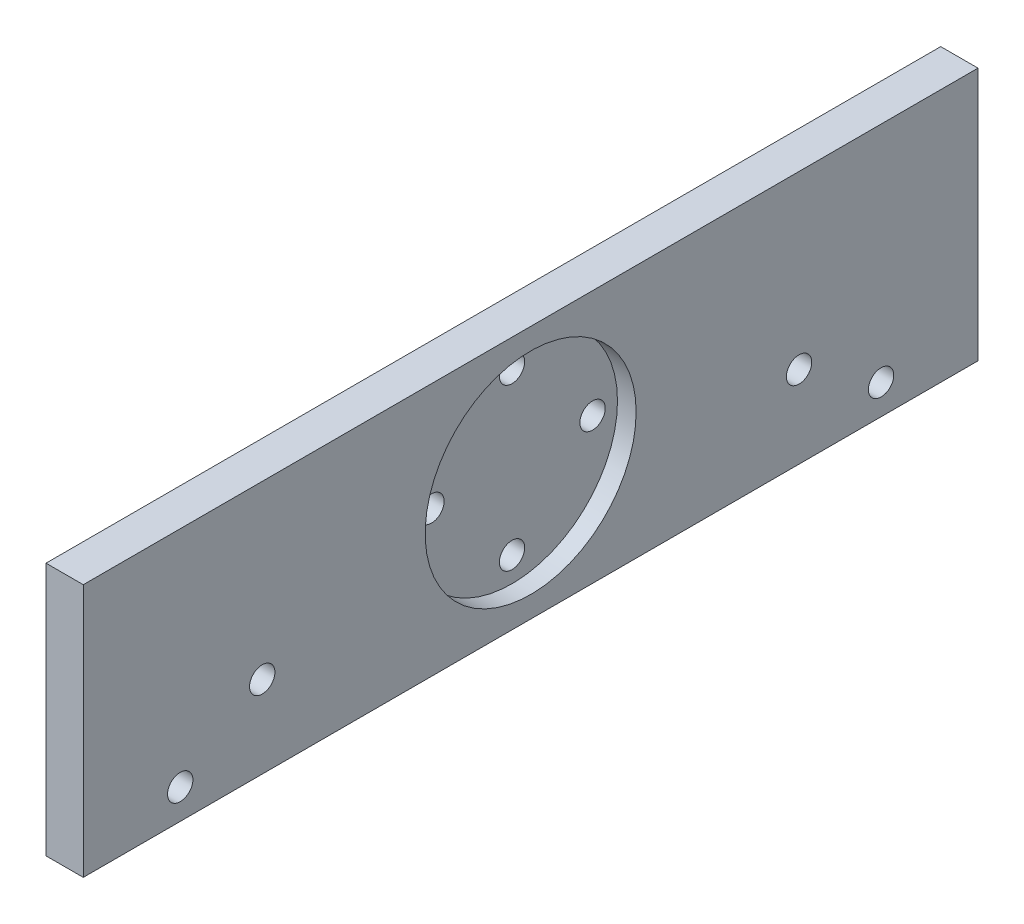
from build123d import *

# Parameters (mm, degrees)
SKETCH1_W                = 120
SKETCH1_H                = 34
BOSS_EXTRUDE1_DEPTH      = 5
CUT_EXTRUDE1_DEPTH       = 2.5
M3_CLEARANCE_HOLE1_D     = 3.4
M3_CLEARANCE_HOLE1_DEPTH = 15
M3_CLEARANCE_HOLE1_TIP   = 1.021463052
M3_CLEARANCE_HOLE3_D     = 3.4
M3_CLEARANCE_HOLE3_DEPTH = 15
M3_CLEARANCE_HOLE3_TIP   = 1.021463052


with BuildPart() as part:
    # Sketch1 → Boss-Extrude1 (new body)
    with BuildSketch(Plane(origin=(0, 0, 0), x_dir=(0, 0, -1), z_dir=(1, 0, 0))):
        with Locations((-60, 17)):
            Rectangle(SKETCH1_W, SKETCH1_H)
    extrude(amount=BOSS_EXTRUDE1_DEPTH)

    # Sketch2 → Cut-Extrude1 (cut)
    with BuildSketch(Plane(origin=(5, 0, 0), x_dir=(0, 0, -1), z_dir=(1, 0, 0))):
        with BuildLine():
            ThreePointArc((-45.85, 17), (-49.994439046, 27.005560954), (-60, 31.15))
            Line((-60, 31.15), (-60, 2.85))
            ThreePointArc((-60, 2.85), (-49.994439046, 6.994439046), (-45.85, 17))
        make_face()
        with BuildLine():
            Line((-60, 2.85), (-60, 31.15))
            ThreePointArc((-60, 31.15), (-74.15, 17), (-60, 2.85))
        make_face()
    extrude(amount=-CUT_EXTRUDE1_DEPTH, mode=Mode.SUBTRACT)

    # M3 Clearance Hole1
    with Locations(Plane(origin=(2.5, 0, 0), x_dir=(0, 0, -1), z_dir=(1, 0, 0))):
        with Locations((-60, 27.8), (-49.2, 17), (-60, 6.2), (-70.8, 17)):
            Hole(M3_CLEARANCE_HOLE1_D / 2, depth=M3_CLEARANCE_HOLE1_DEPTH)
            with Locations((0, 0, -(M3_CLEARANCE_HOLE1_DEPTH + M3_CLEARANCE_HOLE1_TIP / 2))):  # 118° drill point
                Cone(0, M3_CLEARANCE_HOLE1_D / 2, M3_CLEARANCE_HOLE1_TIP, mode=Mode.SUBTRACT)

    # M3 Clearance Hole3
    with Locations(Plane.ZY):
        with Locations((24, 11), (13, 4), (96, 11), (107, 4)):
            Hole(M3_CLEARANCE_HOLE3_D / 2, depth=M3_CLEARANCE_HOLE3_DEPTH)
            with Locations((0, 0, -(M3_CLEARANCE_HOLE3_DEPTH + M3_CLEARANCE_HOLE3_TIP / 2))):  # 118° drill point
                Cone(0, M3_CLEARANCE_HOLE3_D / 2, M3_CLEARANCE_HOLE3_TIP, mode=Mode.SUBTRACT)


solid = part.part
